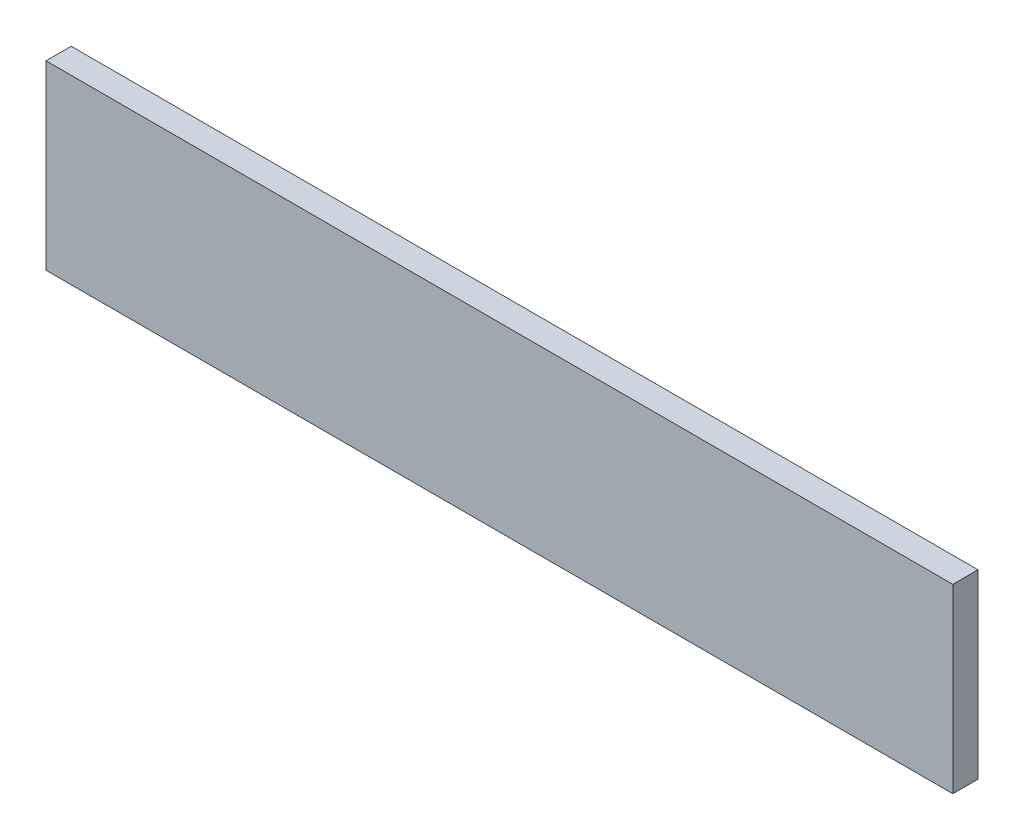
from build123d import *

# Parameters (mm, degrees)
SKETCH1_W           = 114.3
SKETCH1_H           = 22.86
BOSS_EXTRUDE1_DEPTH = 1.5875


with BuildPart() as part:
    # Sketch1 → Boss-Extrude1 (new body, symmetric)
    with BuildSketch(Plane.XY):
        Rectangle(SKETCH1_W, SKETCH1_H)
    extrude(amount=BOSS_EXTRUDE1_DEPTH, both=True)


solid = part.part
